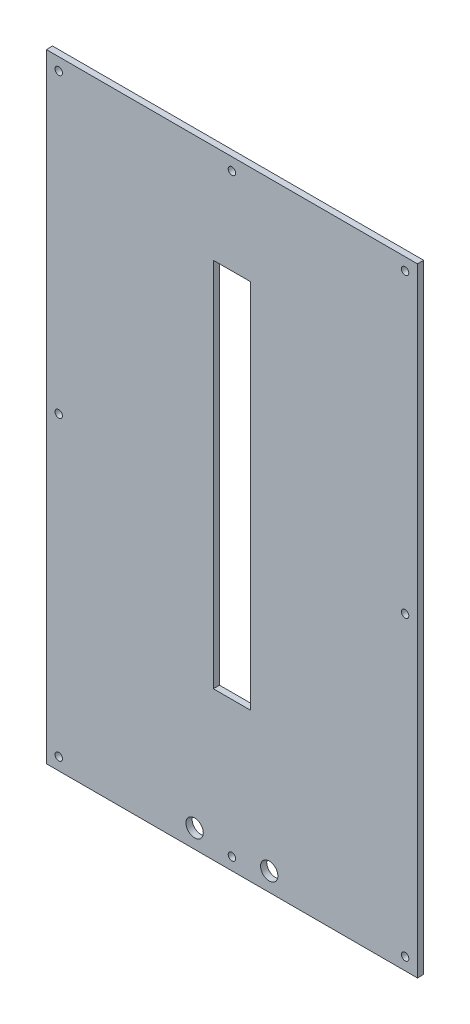
from build123d import *

# Parameters (mm, degrees)
SKETCH1_W           = 300
SKETCH1_H           = 500
SKETCH1_R           = 3
SKETCH1_R_2         = 7
SKETCH1_W_2         = 30
SKETCH1_H_2         = 300
BOSS_EXTRUDE1_DEPTH = 5


with BuildPart() as part:
    # Sketch1 → Boss-Extrude1 (new body)
    with BuildSketch(Plane.XY):
        with Locations((0, -75)):
            Rectangle(SKETCH1_W, SKETCH1_H)
        with Locations((-140, -75)):
            Circle(SKETCH1_R, mode=Mode.SUBTRACT)
        with Locations((140, -315)):
            Circle(SKETCH1_R, mode=Mode.SUBTRACT)
        with Locations((140, -75)):
            Circle(SKETCH1_R, mode=Mode.SUBTRACT)
        with Locations((140, 165)):
            Circle(SKETCH1_R, mode=Mode.SUBTRACT)
        with Locations((0, 165)):
            Circle(SKETCH1_R, mode=Mode.SUBTRACT)
        with Locations((0, -315)):
            Circle(SKETCH1_R, mode=Mode.SUBTRACT)
        with Locations((-140, 165)):
            Circle(SKETCH1_R, mode=Mode.SUBTRACT)
        with Locations((-140, -315)):
            Circle(SKETCH1_R, mode=Mode.SUBTRACT)
        with Locations((-30.15, -310)):
            Circle(SKETCH1_R_2, mode=Mode.SUBTRACT)
        with Locations((30.15, -310)):
            Circle(SKETCH1_R_2, mode=Mode.SUBTRACT)
        with Locations((0, -55)):
            Rectangle(SKETCH1_W_2, SKETCH1_H_2, mode=Mode.SUBTRACT)
    extrude(amount=BOSS_EXTRUDE1_DEPTH)


solid = part.part
